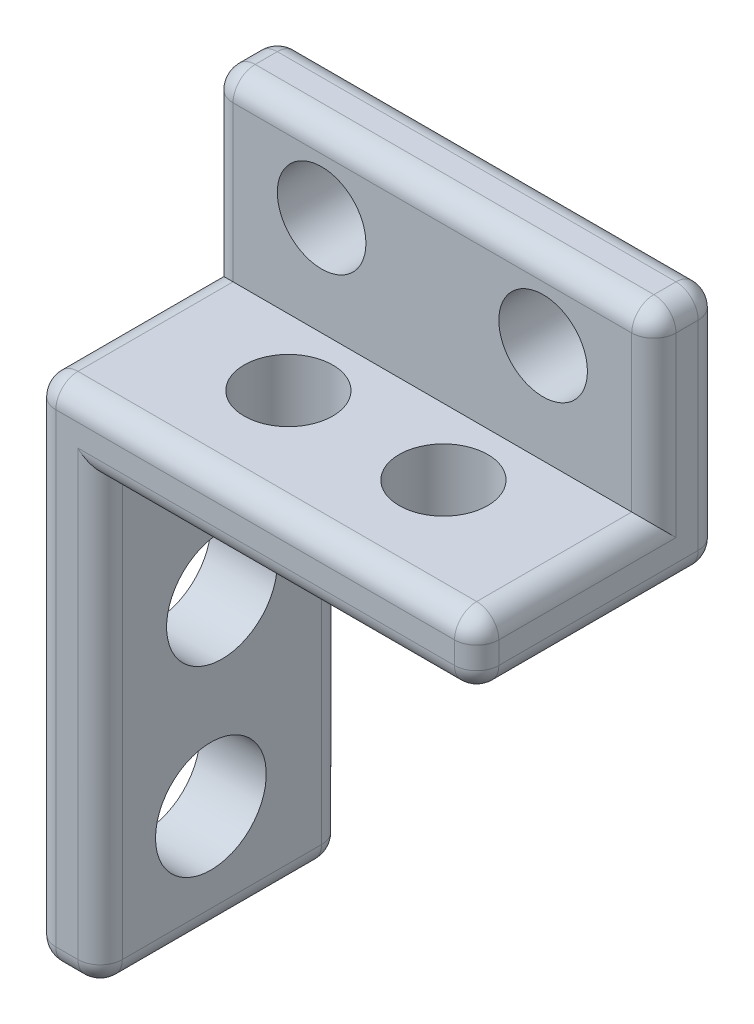
from build123d import *

# Parameters (mm, degrees)
SKETCH1_W           = 3
SKETCH1_H           = 8
SKETCH1_H_2         = 3
SKETCH1_W_2         = 8
BOSS_EXTRUDE1_DEPTH = 20
SKETCH2_R           = 2
CUT_EXTRUDE1_DEPTH  = 4
SKETCH3_R           = 2
CUT_EXTRUDE2_DEPTH  = 4
SKETCH4_W           = 3
SKETCH4_H           = 11
BOSS_EXTRUDE2_DEPTH = 20
SKETCH5_R           = 2.5
CUT_EXTRUDE3_DEPTH  = 21
FILLET1_R           = 1
SKETCH6_R           = 2.5
CUT_EXTRUDE4_DEPTH  = 4


with BuildPart() as part:
    # Sketch1 → Boss-Extrude1 (new body)
    with BuildSketch(Plane(origin=(0, 0, 0), x_dir=(0, 0, -1), z_dir=(1, 0, 0))):
        with Locations((-1.5, 7)):
            Rectangle(SKETCH1_W, SKETCH1_H)
        with Locations((-1.5, 1.5)):
            Rectangle(SKETCH1_W, SKETCH1_H_2)
        with Locations((-7, 1.5)):
            Rectangle(SKETCH1_W_2, SKETCH1_H_2)
    extrude(amount=BOSS_EXTRUDE1_DEPTH)

    # Sketch2 → Cut-Extrude1 (cut, through all)
    with BuildSketch(Plane.XY.offset(3)):
        with Locations((5, 7.5)):
            Circle(SKETCH2_R)
        with Locations((15, 7.5)):
            Circle(SKETCH2_R)
    extrude(amount=-CUT_EXTRUDE1_DEPTH, mode=Mode.SUBTRACT)

    # Sketch3 → Cut-Extrude2 (cut, through all)
    with BuildSketch(Plane(origin=(0, 3, 0), x_dir=(1, 0, 0), z_dir=(0, 1, 0))):
        with Locations((6.5, -6)):
            Circle(SKETCH3_R)
        with Locations((13.5, -6)):
            Circle(SKETCH3_R)
    extrude(amount=-CUT_EXTRUDE2_DEPTH, mode=Mode.SUBTRACT)

    # Sketch4 → Boss-Extrude2 (add)
    with BuildSketch(Plane.XZ):
        with Locations((1.5, 5.5)):
            Rectangle(SKETCH4_W, SKETCH4_H)
    extrude(amount=BOSS_EXTRUDE2_DEPTH)

    # Sketch5 → Cut-Extrude3 (cut, through all)
    with BuildSketch(Plane.ZY):
        with Locations((6, -15)):
            Circle(SKETCH5_R)
    extrude(amount=-CUT_EXTRUDE3_DEPTH, mode=Mode.SUBTRACT)

    # Fillet1
    fillet1_edges = [part.edges().sort_by_distance(p)[0] for p in [
        (20, 3, 7),
        (0, 3, 7),
        (0, 7, 3),
        (10, 11, 3),
        (10, 11, 0),
        (11.5, 0, 0),
        (11.5, 0, 11),
        (10, 3, 11),
        (20, 1.5, 11),
        (20, 0, 5.5),
        (20, 5.5, 0),
        (20, 11, 1.5),
        (3, -10, 0),
        (3, -10, 11),
        (0, -20, 5.5),
        (1.5, -20, 0),
        (3, -20, 5.5),
        (1.5, -20, 11),
        (20, 7, 3),
        (0, 11, 1.5),
        (0, -4.5, 0),
        (0, -8.5, 11),
    ]]
    fillet(fillet1_edges, radius=FILLET1_R)

    # Sketch6 → Cut-Extrude4 (cut, through all)
    with BuildSketch(Plane(origin=(3, 0, 0), x_dir=(0, 0, -1), z_dir=(1, 0, 0))):
        with Locations((-5.5, -7)):
            Circle(SKETCH6_R)
    extrude(amount=-CUT_EXTRUDE4_DEPTH, mode=Mode.SUBTRACT)


solid = part.part
